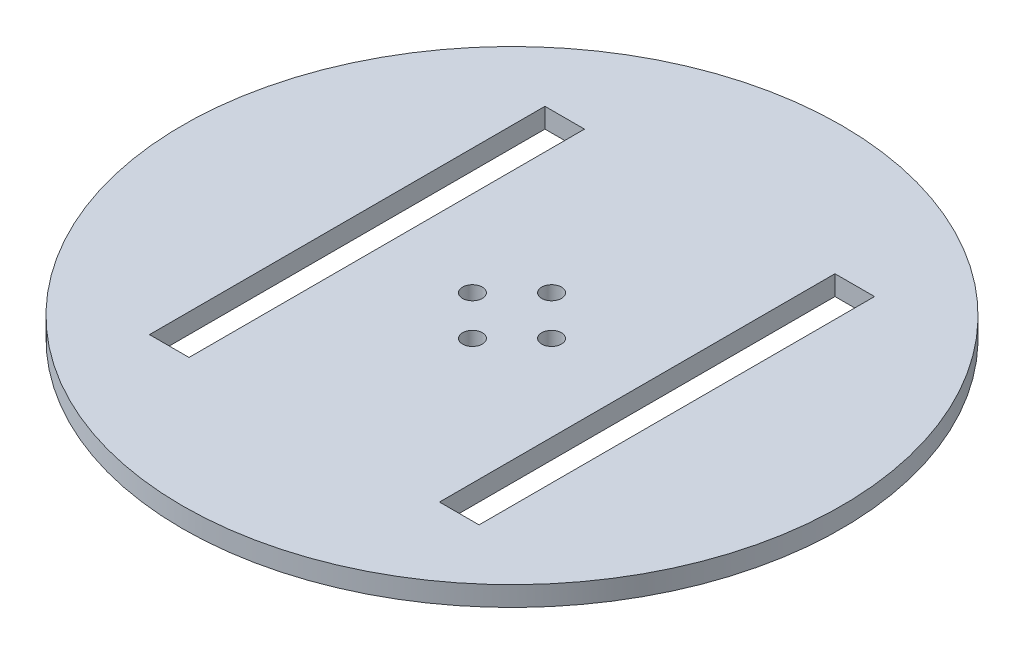
from build123d import *

# Parameters (mm, degrees)
CROQUIS1_R              = 50
SALIENTE_EXTRUIR1_DEPTH = 3
CORTAR_EXTRUIR1_REACH   = 5
CROQUIS2_R              = 1.5
CORTAR_EXTRUIR2_REACH   = 5
CROQUIS3_W              = 6
CROQUIS3_H              = 60


with BuildPart() as part:
    # Croquis1 → Saliente-Extruir1 (new body)
    with BuildSketch(Plane(origin=(0, 0, 0), x_dir=(1, 0, 0), z_dir=(0, 1, 0))):
        Circle(CROQUIS1_R)
    extrude(amount=SALIENTE_EXTRUIR1_DEPTH)

    # Croquis2 → Cortar-Extruir1 (cut, up to next)
    with BuildSketch(Plane(origin=(0, 3, 0), x_dir=(1, 0, 0), z_dir=(0, 1, 0)), mode=Mode.PRIVATE) as cortar_extruir1_sk1:
        with Locations((0, 6)):
            Circle(CROQUIS2_R)
    cortar_extruir1_tool1 = extrude(cortar_extruir1_sk1.sketch, amount=-CORTAR_EXTRUIR1_REACH, mode=Mode.PRIVATE) & part.part
    add(cortar_extruir1_tool1.solids().sort_by_distance((0, 3, -6))[0], mode=Mode.SUBTRACT)
    # Croquis2 → Cortar-Extruir1 (cut, up to next)
    with BuildSketch(Plane(origin=(0, 3, 0), x_dir=(1, 0, 0), z_dir=(0, 1, 0)), mode=Mode.PRIVATE) as cortar_extruir1_sk2:
        with Locations((6, 0)):
            Circle(CROQUIS2_R)
    cortar_extruir1_tool2 = extrude(cortar_extruir1_sk2.sketch, amount=-CORTAR_EXTRUIR1_REACH, mode=Mode.PRIVATE) & part.part
    add(cortar_extruir1_tool2.solids().sort_by_distance((6, 3, 0))[0], mode=Mode.SUBTRACT)
    # Croquis2 → Cortar-Extruir1 (cut, up to next)
    with BuildSketch(Plane(origin=(0, 3, 0), x_dir=(1, 0, 0), z_dir=(0, 1, 0)), mode=Mode.PRIVATE) as cortar_extruir1_sk3:
        with Locations((0, -6)):
            Circle(CROQUIS2_R)
    cortar_extruir1_tool3 = extrude(cortar_extruir1_sk3.sketch, amount=-CORTAR_EXTRUIR1_REACH, mode=Mode.PRIVATE) & part.part
    add(cortar_extruir1_tool3.solids().sort_by_distance((0, 3, 6))[0], mode=Mode.SUBTRACT)
    # Croquis2 → Cortar-Extruir1 (cut, up to next)
    with BuildSketch(Plane(origin=(0, 3, 0), x_dir=(1, 0, 0), z_dir=(0, 1, 0)), mode=Mode.PRIVATE) as cortar_extruir1_sk4:
        with Locations((-6, 0)):
            Circle(CROQUIS2_R)
    cortar_extruir1_tool4 = extrude(cortar_extruir1_sk4.sketch, amount=-CORTAR_EXTRUIR1_REACH, mode=Mode.PRIVATE) & part.part
    add(cortar_extruir1_tool4.solids().sort_by_distance((-6, 3, 0))[0], mode=Mode.SUBTRACT)

    # Croquis3 → Cortar-Extruir2 (cut, up to next)
    with BuildSketch(Plane(origin=(0, 3, 0), x_dir=(1, 0, 0), z_dir=(0, 1, 0)), mode=Mode.PRIVATE) as cortar_extruir2_sk1:
        with Locations((22, 0)):
            Rectangle(CROQUIS3_W, CROQUIS3_H)
    cortar_extruir2_tool1 = extrude(cortar_extruir2_sk1.sketch, amount=-CORTAR_EXTRUIR2_REACH, mode=Mode.PRIVATE) & part.part
    add(cortar_extruir2_tool1.solids().sort_by_distance((22, 3, 0))[0], mode=Mode.SUBTRACT)
    # Croquis3 → Cortar-Extruir2 (cut, up to next)
    with BuildSketch(Plane(origin=(0, 3, 0), x_dir=(1, 0, 0), z_dir=(0, 1, 0)), mode=Mode.PRIVATE) as cortar_extruir2_sk2:
        with Locations((-22, 0)):
            Rectangle(CROQUIS3_W, CROQUIS3_H)
    cortar_extruir2_tool2 = extrude(cortar_extruir2_sk2.sketch, amount=-CORTAR_EXTRUIR2_REACH, mode=Mode.PRIVATE) & part.part
    add(cortar_extruir2_tool2.solids().sort_by_distance((-22, 3, 0))[0], mode=Mode.SUBTRACT)


solid = part.part
